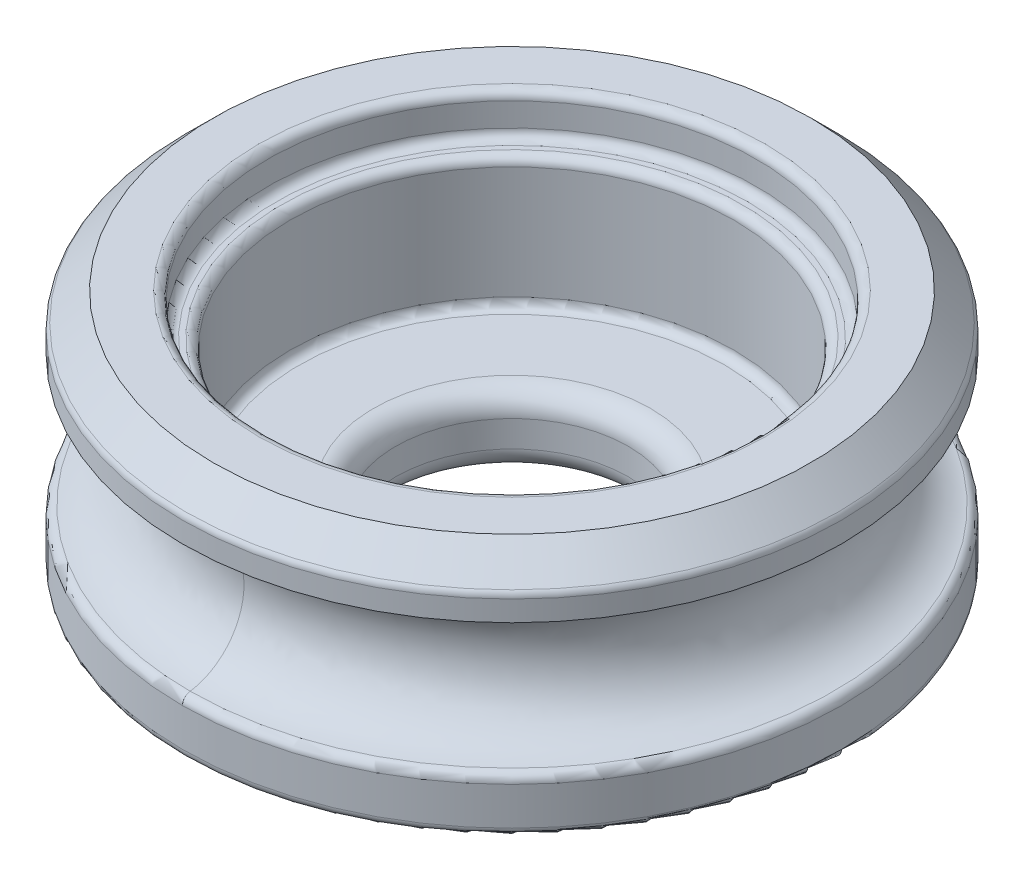
from build123d import *

# Parameters (mm, degrees)
SKETCH2_R           = 9.525
BOSS_EXTRUDE1_DEPTH = 6.985
SKETCH3_R           = 6.4135
CUT_EXTRUDE1_DEPTH  = 6.985
SKETCH4_R           = 7.0723125
CUT_EXTRUDE2_DEPTH  = 1.190625
SKETCH6_R           = 6.4135
SKETCH6_R_2         = 3.3655
BOSS_EXTRUDE2_DEPTH = 2.032
SKETCH7_RX          = 1.905
SKETCH7_RY          = 1.778
FILLET1_R           = 0.254
CHAMFER1_SIZE       = 0.889
FILLET3_R           = 0.254
FILLET4_R           = 0.635
FILLET5_R           = 0.254


with BuildPart() as part:
    # Sketch2 → Boss-Extrude1 (new body)
    with BuildSketch(Plane(origin=(0, 0, 0), x_dir=(1, 0, 0), z_dir=(0, 1, 0))):
        with Locations(Location((0, 0, 0), (0, 0, 270))):
            Circle(SKETCH2_R)
    extrude(amount=BOSS_EXTRUDE1_DEPTH)

    # Sketch3 → Cut-Extrude1 (cut)
    with BuildSketch(Plane(origin=(0, 6.985, 0), x_dir=(1, 0, 0), z_dir=(0, 1, 0))):
        with Locations(Location((0, 0, 0), (0, 0, 270))):
            Circle(SKETCH3_R)
    extrude(amount=-CUT_EXTRUDE1_DEPTH, mode=Mode.SUBTRACT)

    # Sketch4 → Cut-Extrude2 (cut)
    with BuildSketch(Plane(origin=(0, 6.985, 0), x_dir=(1, 0, 0), z_dir=(0, 1, 0))):
        with Locations(Location((0, 0, 0), (0, 0, 270))):
            Circle(SKETCH4_R)
    extrude(amount=-CUT_EXTRUDE2_DEPTH, mode=Mode.SUBTRACT)

    # Sketch6 → Boss-Extrude2 (add)
    with BuildSketch(Plane.XZ):
        with Locations(Location((0, 0, 0), (0, 0, 90))):
            Circle(SKETCH6_R)
        with Locations(Location((0, 0, 0), (0, 0, 270))):
            Circle(SKETCH6_R_2, mode=Mode.SUBTRACT)
    extrude(amount=-BOSS_EXTRUDE2_DEPTH)

    # Cut-Sweep2: sweep along a curve in space
    with BuildLine() as cut_sweep2_path:
        ThreePointArc((0, 0, 9.525), (6.735192091, 0, 6.735192091), (9.525, 0, 0))
        ThreePointArc((9.525, 0, 0), (6.735192091, 0, -6.735192091), (0, 0, -9.525))
        ThreePointArc((0, 0, -9.525), (-6.735192091, 0, -6.735192091), (-9.525, 0, 0))
        ThreePointArc((-9.525, 0, 0), (-6.735192091, 0, 6.735192091), (0, 0, 9.525))
    # Sketch7 → Cut-Sweep2 (sweep, cut)
    with BuildSketch(Plane(origin=(0, 0, 0), x_dir=(0, 0, -1), z_dir=(1, 0, 0))):
        with Locations(Location((9.525, 3.4925), (0, 0, 90))):
            Ellipse(SKETCH7_RX, SKETCH7_RY)
    sweep(path=cut_sweep2_path.line, mode=Mode.SUBTRACT)

    # Fillet1
    fillet1_edges = [part.edges().sort_by_distance(p)[0] for p in [
        (0, 6.985, -7.0723125),
        (0, 5.794375, -7.0723125),
        (0, 5.794375, -6.4135),
    ]]
    fillet(fillet1_edges, radius=FILLET1_R)

    # Chamfer1
    chamfer1_edges = [part.edges().sort_by_distance(p)[0] for p in [
        (0, 6.985, -9.525),
    ]]
    chamfer(chamfer1_edges, length=CHAMFER1_SIZE)

    # Fillet3
    fillet3_edges = [part.edges().sort_by_distance(p)[0] for p in [
        (0, 0, -9.525),
        (6.735192091, 1.5875, -6.735192091),
        (-6.735192091, 1.5875, -6.735192091),
        (0, 6.096, -9.525),
    ]]
    fillet(fillet3_edges, radius=FILLET3_R)

    # Fillet4
    fillet4_edges = [part.edges().sort_by_distance(p)[0] for p in [
        (0, 2.032, 3.3655),
        (0, 0, 3.3655),
    ]]
    fillet(fillet4_edges, radius=FILLET4_R)

    # Fillet5
    fillet5_edges = [part.edges().sort_by_distance(p)[0] for p in [
        (0, 2.032, -6.4135),
    ]]
    fillet(fillet5_edges, radius=FILLET5_R)


solid = part.part
